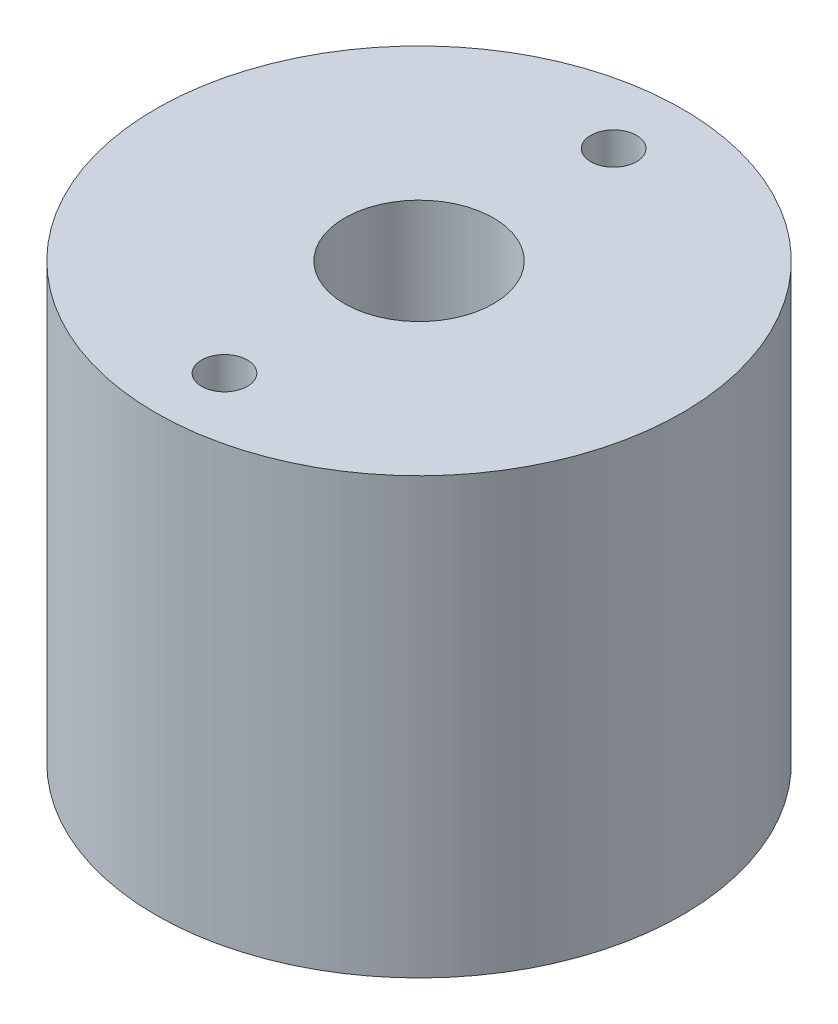
from build123d import *

# Parameters (mm, degrees)
SKETCH1_R           = 11.5
BOSS_EXTRUDE1_DEPTH = 19
SKETCH2_R           = 1
SKETCH2_R_2         = 3.25
CUT_EXTRUDE1_DEPTH  = 8.5


with BuildPart() as part:
    # Sketch1 → Boss-Extrude1 (new body)
    with BuildSketch(Plane(origin=(0, 0, 0), x_dir=(1, 0, 0), z_dir=(0, 1, 0))):
        Circle(SKETCH1_R)
    extrude(amount=BOSS_EXTRUDE1_DEPTH)

    # Sketch2 → Cut-Extrude1 (cut)
    with BuildSketch(Plane(origin=(0, 19, 0), x_dir=(1, 0, 0), z_dir=(0, 1, 0))):
        with Locations((0, 8.5)):
            Circle(SKETCH2_R)
        with Locations((0, -8.5)):
            Circle(SKETCH2_R)
        Circle(SKETCH2_R_2)
    extrude(amount=-CUT_EXTRUDE1_DEPTH, mode=Mode.SUBTRACT)


solid = part.part
